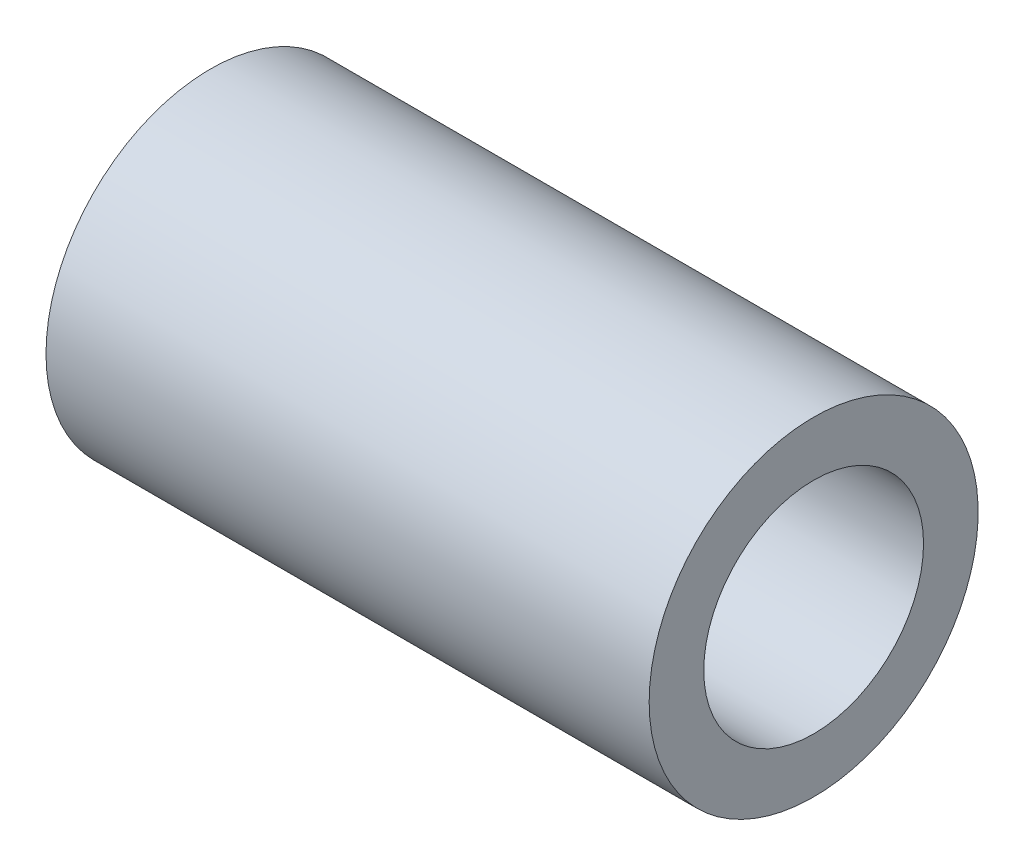
from build123d import *

# Parameters (mm, degrees)
SKETCH1_W = 34.925
SKETCH1_H = 3.1623


with BuildPart() as part:
    # Sketch1 → Revolve1 (revolve)
    with BuildSketch(Plane.XY):
        with Locations((17.4625, 7.94385)):
            Rectangle(SKETCH1_W, SKETCH1_H)
    revolve(axis=Axis((0, 0, 0), (1, 0, 0)))


solid = part.part
